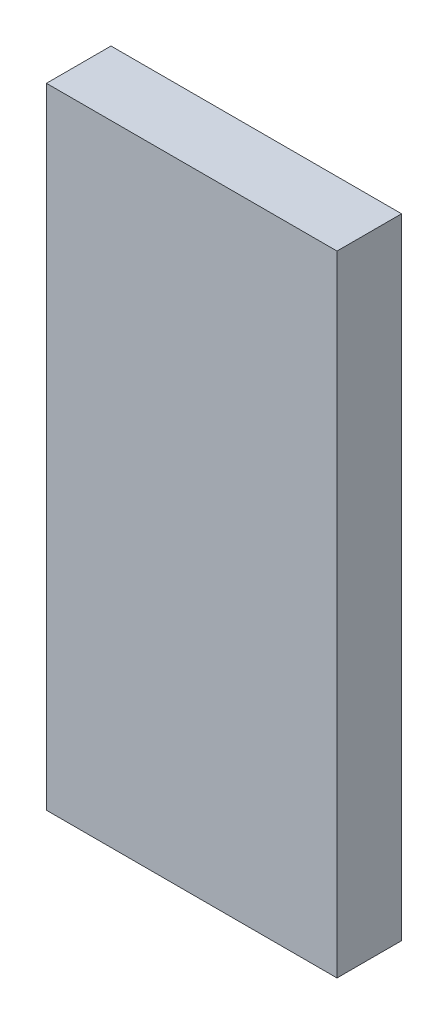
from build123d import *

# Parameters (mm, degrees)
SKETCH1_W           = 18
SKETCH1_H           = 39
BOSS_EXTRUDE1_DEPTH = 4


with BuildPart() as part:
    # Sketch1 → Boss-Extrude1 (new body)
    with BuildSketch(Plane.XY):
        with Locations((9, 19.5)):
            Rectangle(SKETCH1_W, SKETCH1_H)
    extrude(amount=BOSS_EXTRUDE1_DEPTH)


solid = part.part
